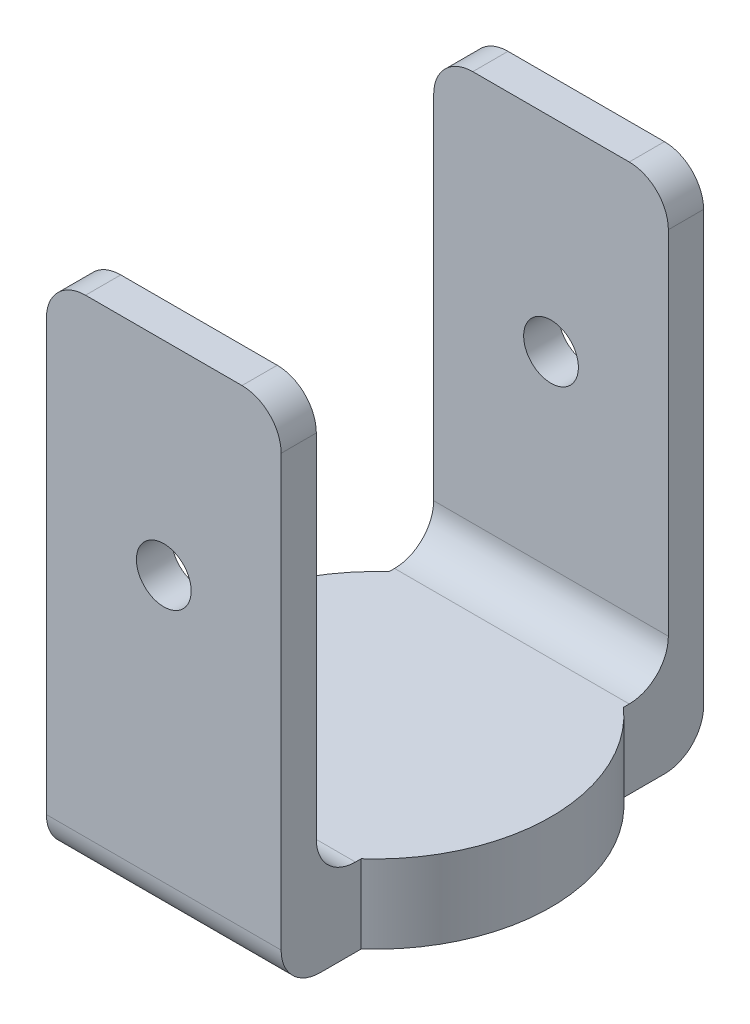
from build123d import *

# Parameters (mm, degrees)
BOSS_EXTRUDE1_DEPTH = 30
SKETCH3_R           = 22.5
BOSS_EXTRUDE2_DEPTH = 10
FILLET2_R           = 5
SKETCH4_R           = 3.5
CUT_EXTRUDE1_DEPTH  = 70


with BuildPart() as part:
    # Sketch1 → Boss-Extrude1 (new body)
    with BuildSketch(Plane(origin=(0, 0, 0), x_dir=(0, 0, -1), z_dir=(1, 0, 0))):
        Polygon((0, 0), (0, -65), (54, -65), (54, 0), (49.5, 0), (49.5, -55), (4.5, -55), (4.5, 0), align=None)
    extrude(amount=BOSS_EXTRUDE1_DEPTH)

    # Sketch3 → Boss-Extrude2 (add)
    with BuildSketch(Plane.XZ.offset(65)):
        with Locations((15, -27)):
            Circle(SKETCH3_R)
    extrude(amount=-BOSS_EXTRUDE2_DEPTH)

    # Fillet2
    fillet2_edges = [part.edges().sort_by_distance(p)[0] for p in [
        (0, 0, -2.25),
        (15, -55, -4.5),
        (15, -55, -49.5),
        (15, -65, -54),
        (15, -65, 0),
        (30, 0, -51.75),
        (30, 0, -2.25),
        (0, 0, -51.75),
    ]]
    fillet(fillet2_edges, radius=FILLET2_R)

    # Sketch4 → Cut-Extrude1 (cut)
    with BuildSketch(Plane(origin=(0, 0, -54), x_dir=(-1, 0, 0), z_dir=(0, 0, -1))):
        with Locations((-15, -26)):
            Circle(SKETCH4_R)
    extrude(amount=-CUT_EXTRUDE1_DEPTH, mode=Mode.SUBTRACT)


solid = part.part
